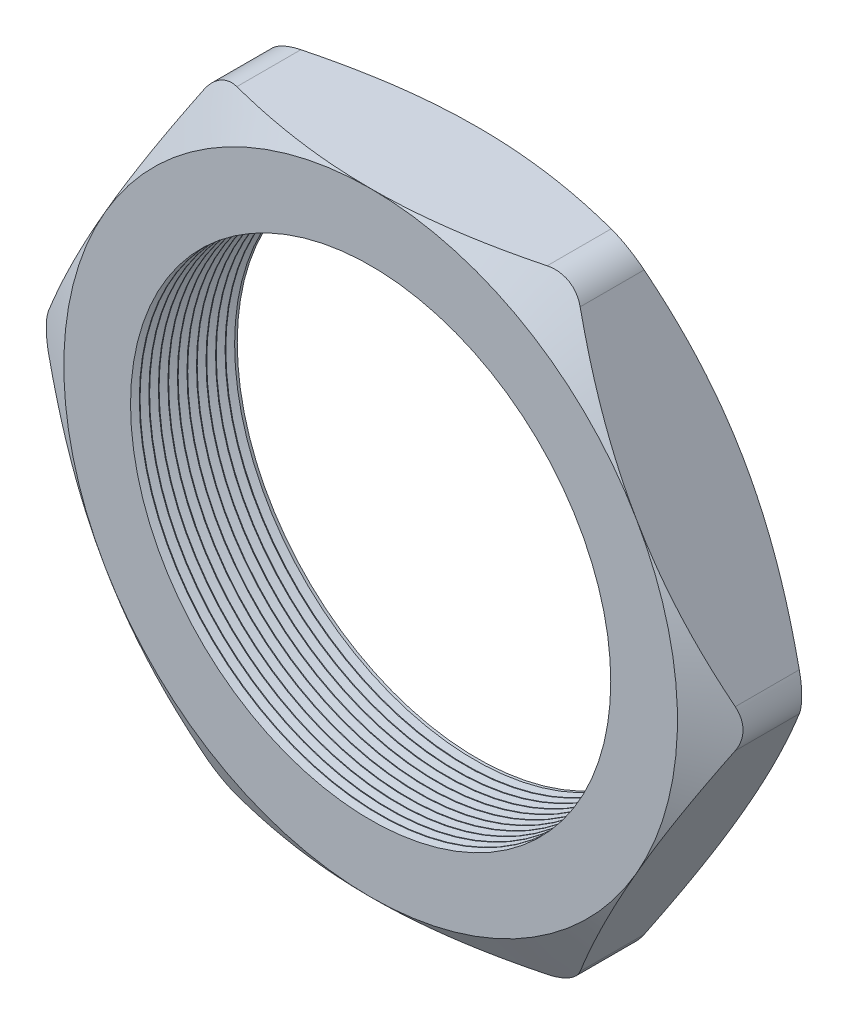
from build123d import *

# Parameters (mm, degrees)
SKETCH1_R          = 16.002
EXTRUDE1_DEPTH     = 7.112
SKETCH2_OUTSIDE_W  = 89.894
SKETCH2_OUTSIDE_H  = 83.568
SKETCH2_OUTSIDE_R  = 20.447
CUT_EXTRUDE1_DEPTH = 8.112
CUT_EXTRUDE1_DRAFT = -60
SKETCH3_OUTSIDE_W  = 89.894
SKETCH3_OUTSIDE_H  = 83.568
SKETCH3_OUTSIDE_R  = 20.447
CUT_EXTRUDE2_DEPTH = 8.112
CUT_EXTRUDE2_DRAFT = -60
FILLET1_R          = 2.54
LPATTERN1_COUNT    = 11
LPATTERN1_PITCH    = 0.635


with BuildPart() as part:
    # Sketch1 → Extrude1 (new body)
    with BuildSketch(Plane.XY):
        Polygon((-23.610161908, 0), (-11.805080954, -20.447), (11.805080954, -20.447), (23.610161908, 0), (11.805080954, 20.447), (-11.805080954, 20.447), align=None)
        Circle(SKETCH1_R, mode=Mode.SUBTRACT)
    extrude(amount=EXTRUDE1_DEPTH)


with BuildPart() as cut_extrude1_tool:
    # Sketch2 outside → Cut-Extrude1 (with draft: the straight prism first)
    with BuildSketch(Plane.XY.offset(7.112)):
        Rectangle(SKETCH2_OUTSIDE_W, SKETCH2_OUTSIDE_H)
        Circle(SKETCH2_OUTSIDE_R, mode=Mode.SUBTRACT)
    extrude(amount=-CUT_EXTRUDE1_DEPTH)
    # Cut-Extrude1: the draft: its side faces are tilted about the plane it starts from
    cut_extrude1_sides = [cut_extrude1_tool.faces().sort_by_distance(p)[0] for p in [
        (0, -41.784, 3.056),
        (44.947, 0, 3.056),
        (0, 41.784, 3.056),
        (-44.947, 0, 3.056),
        (-20.447, 0, 3.056),
    ]]
    draft(cut_extrude1_sides, Plane.XY.offset(7.112), CUT_EXTRUDE1_DRAFT)


with BuildPart() as part_1:
    add(part.part)

    # Cut-Extrude1: cut by cut_extrude1_tool
    add(cut_extrude1_tool.part, mode=Mode.SUBTRACT)


with BuildPart() as cut_extrude2_tool:
    # Sketch3 outside → Cut-Extrude2 (with draft: the straight prism first)
    with BuildSketch(Plane(origin=(0, 0, 0), x_dir=(-1, 0, 0), z_dir=(0, 0, -1))):
        Rectangle(SKETCH3_OUTSIDE_W, SKETCH3_OUTSIDE_H)
        Circle(SKETCH3_OUTSIDE_R, mode=Mode.SUBTRACT)
    extrude(amount=-CUT_EXTRUDE2_DEPTH)
    # Cut-Extrude2: the draft: its side faces are tilted about the plane it starts from
    cut_extrude2_sides = [cut_extrude2_tool.faces().sort_by_distance(p)[0] for p in [
        (0, -41.784, 4.056),
        (-44.947, 0, 4.056),
        (0, 41.784, 4.056),
        (44.947, 0, 4.056),
        (20.447, 0, 4.056),
    ]]
    draft(cut_extrude2_sides, Plane(origin=(0, 0, 0), x_dir=(-1, 0, 0), z_dir=(0, 0, -1)), CUT_EXTRUDE2_DRAFT)


with BuildPart() as part_2:
    add(part_1.part)

    # Cut-Extrude2: cut by cut_extrude2_tool
    add(cut_extrude2_tool.part, mode=Mode.SUBTRACT)

    # Fillet1
    fillet1_edges = [part_2.edges().sort_by_distance(p)[0] for p in [
        (23.610161908, 0, 3.556),
        (11.805080954, -20.447, 3.556),
        (-11.805080954, -20.447, 3.556),
        (-23.610161908, 0, 3.556),
        (-11.805080954, 20.447, 3.556),
        (11.805080954, 20.447, 3.556),
    ]]
    fillet(fillet1_edges, radius=FILLET1_R)

    # Sketch4 → Cut-Revolve1 (revolve, cut)
    with BuildSketch(Plane(origin=(0, 0, 0), x_dir=(1, 0, 0), z_dir=(0, 1, 0)), mode=Mode.PRIVATE) as cut_revolve1_sk:
        Polygon((-16.002, -7.112), (-16.002, -6.525412127), (-16.51, -6.818706063), align=None)
    cut_revolve1 = revolve(cut_revolve1_sk.sketch.rotate(Axis((0, 0, 0), (0, 0, 1)), 180), axis=Axis((0, 0, 0), (0, 0, 1)), mode=Mode.SUBTRACT)  # turned: the seam where the file's is

    # LPattern1: Cut-Revolve1 ×11
    with Locations(*[(0, 0, -i * LPATTERN1_PITCH) for i in range(1, LPATTERN1_COUNT)]):
        add(cut_revolve1, mode=Mode.SUBTRACT)


solid = part_2.part
